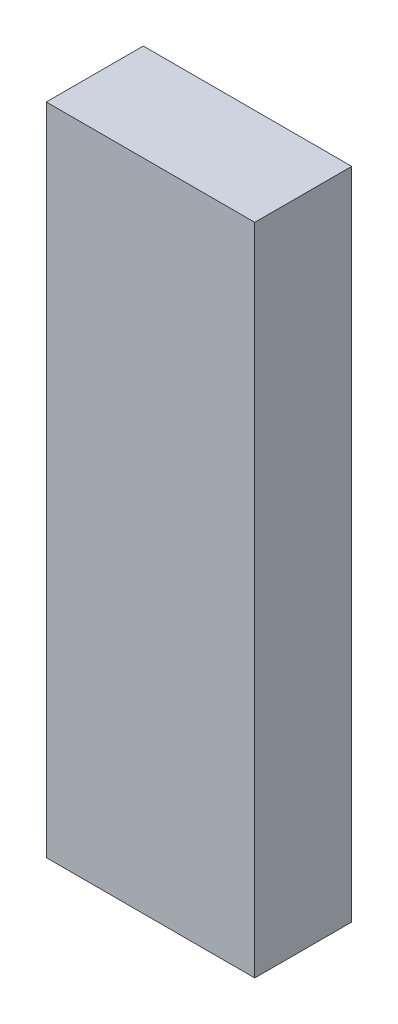
from build123d import *

# Parameters (mm, degrees)
SKETCH_1_W      = 43
SKETCH_1_H      = 135
EXTRUDE_1_DEPTH = 20


with BuildPart() as part:
    # 草图1 → 凸台-拉伸1 (new body)
    with BuildSketch(Plane.XY):
        with Locations((162.189656408, 21.927523728)):
            Rectangle(SKETCH_1_W, SKETCH_1_H)
    extrude(amount=EXTRUDE_1_DEPTH)


solid = part.part
